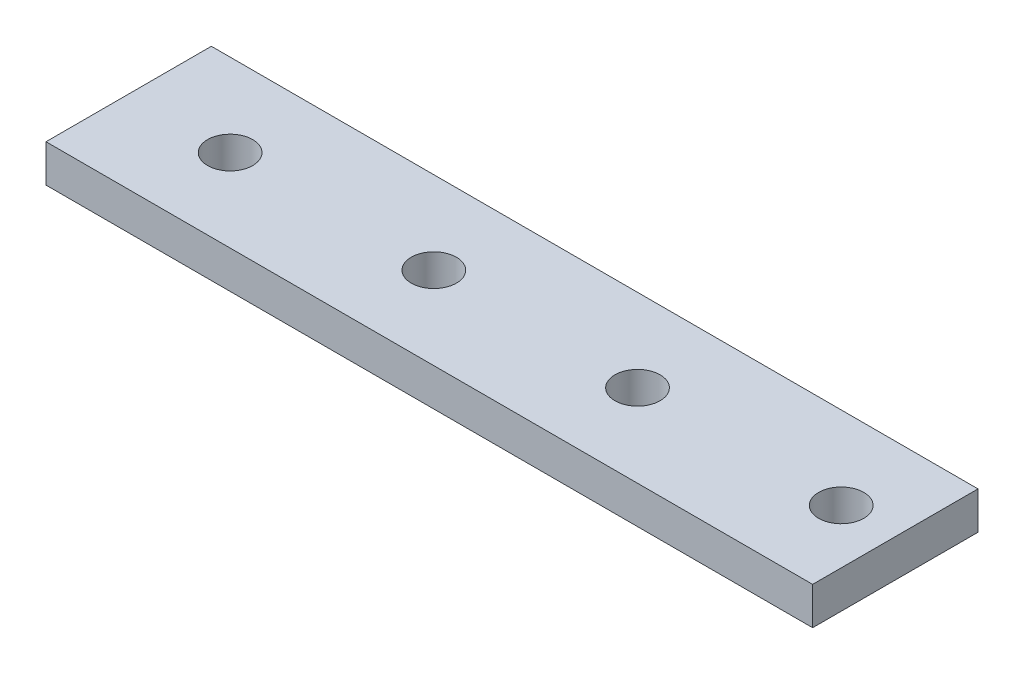
from build123d import *

# Parameters (mm, degrees)
SKETCH1_W           = 102
SKETCH1_H           = 22
SKETCH1_R           = 3
BOSS_EXTRUDE1_DEPTH = 5


with BuildPart() as part:
    # Sketch1 → Boss-Extrude1 (new body)
    with BuildSketch(Plane(origin=(0, 0, 0), x_dir=(1, 0, 0), z_dir=(0, 1, 0))):
        Rectangle(SKETCH1_W, SKETCH1_H)
        with Locations((-37.5, 0)):
            Circle(SKETCH1_R, mode=Mode.SUBTRACT)
        with Locations((-10.4, 0)):
            Circle(SKETCH1_R, mode=Mode.SUBTRACT)
        with Locations((16.7, 0)):
            Circle(SKETCH1_R, mode=Mode.SUBTRACT)
        with Locations((43.8, 0)):
            Circle(SKETCH1_R, mode=Mode.SUBTRACT)
    extrude(amount=BOSS_EXTRUDE1_DEPTH)


solid = part.part
